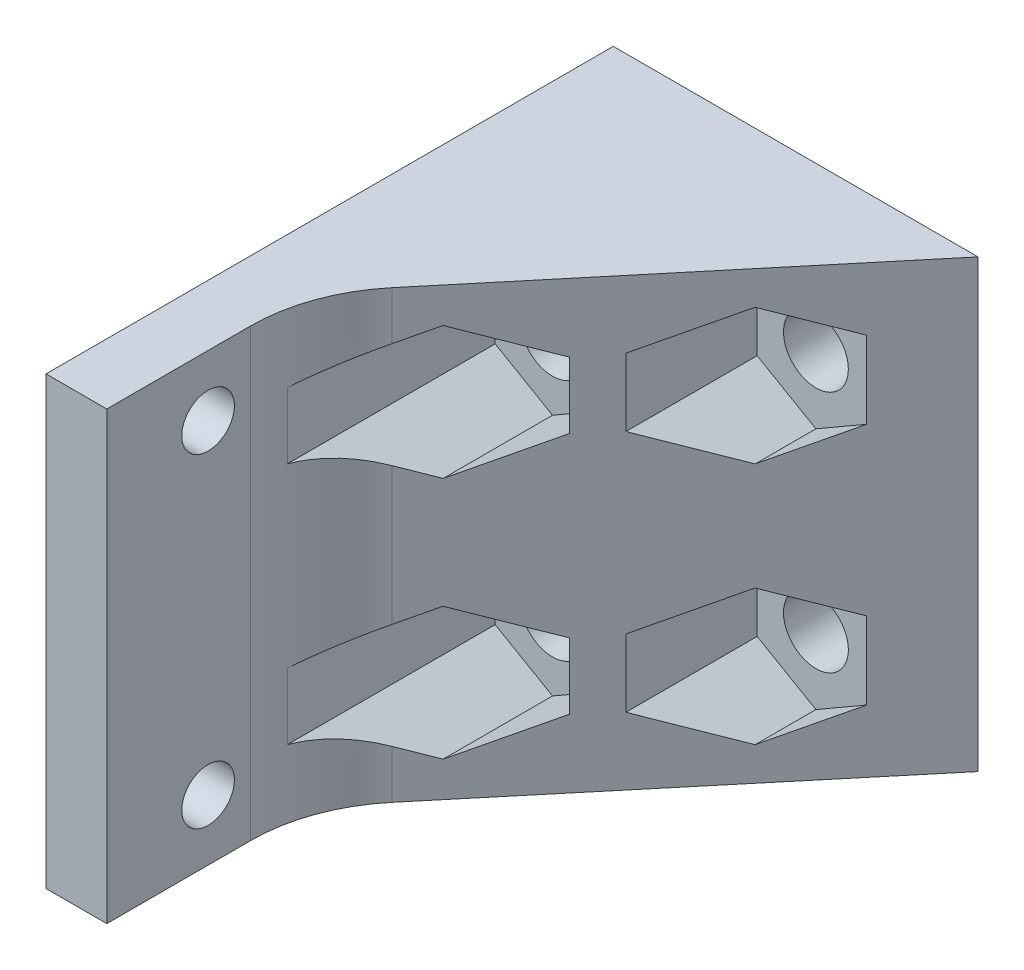
from build123d import *

# Parameters (mm, degrees)
SKETCH1_W           = 28
SKETCH1_H           = 22
SKETCH1_R           = 1.3
BOSS_EXTRUDE1_DEPTH = 3
BOSS_EXTRUDE3_DEPTH = 22
FILLET1_R           = 8
SKETCH4_R           = 1.6
CUT_EXTRUDE1_DEPTH  = 29
CUT_EXTRUDE2_DEPTH  = 20
CUT_EXTRUDE3_DEPTH  = 26


with BuildPart() as part:
    # Sketch1 → Boss-Extrude1 (new body)
    with BuildSketch(Plane(origin=(0, 0, 0), x_dir=(0, 0, -1), z_dir=(1, 0, 0))):
        with Locations((14, 11)):
            Rectangle(SKETCH1_W, SKETCH1_H)
        with Locations((5, 19)):
            Circle(SKETCH1_R, mode=Mode.SUBTRACT)
        with Locations((5, 3)):
            Circle(SKETCH1_R, mode=Mode.SUBTRACT)
    extrude(amount=BOSS_EXTRUDE1_DEPTH)

    # Sketch3 → Boss-Extrude3 (add)
    with BuildSketch(Plane(origin=(0, 0, 0), x_dir=(1, 0, 0), z_dir=(0, 1, 0))):
        Polygon((3, 28), (18, 28), (3, 10), align=None)
    extrude(amount=BOSS_EXTRUDE3_DEPTH)

    # Fillet1
    fillet1_edges = [part.edges().sort_by_distance(p)[0] for p in [
        (3, 11, -10),
    ]]
    fillet(fillet1_edges, radius=FILLET1_R)

    # Sketch4 → Cut-Extrude1 (cut, through all)
    with BuildSketch(Plane(origin=(0, 0, -28), x_dir=(-1, 0, 0), z_dir=(0, 0, -1))):
        with Locations((-6, 17)):
            Circle(SKETCH4_R)
        with Locations((-6, 5)):
            Circle(SKETCH4_R)
        with Locations((-13, 17)):
            Circle(SKETCH4_R)
        with Locations((-13, 5)):
            Circle(SKETCH4_R)
    extrude(amount=-CUT_EXTRUDE1_DEPTH, mode=Mode.SUBTRACT)

    # Sketch5 → Cut-Extrude2 (cut, through all)
    with BuildSketch(Plane.XY.offset(-19)):
        Polygon((3.169500163, 3.365810157), (3.169500163, 6.634189843), (6, 8.268379685), (8.830499837, 6.634189843), (8.830499837, 3.365810157), (6, 1.731620315), align=None)
        Polygon((3.169500163, 15.365810157), (6, 13.731620315), (8.830499837, 15.365810157), (8.830499837, 18.634189843), (6, 20.268379685), (3.169500163, 18.634189843), align=None)
    extrude(amount=CUT_EXTRUDE2_DEPTH, mode=Mode.SUBTRACT)

    # Sketch6 → Cut-Extrude3 (cut, through all)
    with BuildSketch(Plane.XY.offset(-25)):
        Polygon((10.1, 15.325684219), (13, 13.651368439), (15.9, 15.325684219), (15.9, 18.674315781), (13, 20.348631561), (10.1, 18.674315781), align=None)
        Polygon((10.1, 3.325684219), (10.1, 6.674315781), (13, 8.348631561), (15.9, 6.674315781), (15.9, 3.325684219), (13, 1.651368439), align=None)
    extrude(amount=CUT_EXTRUDE3_DEPTH, mode=Mode.SUBTRACT)


solid = part.part
